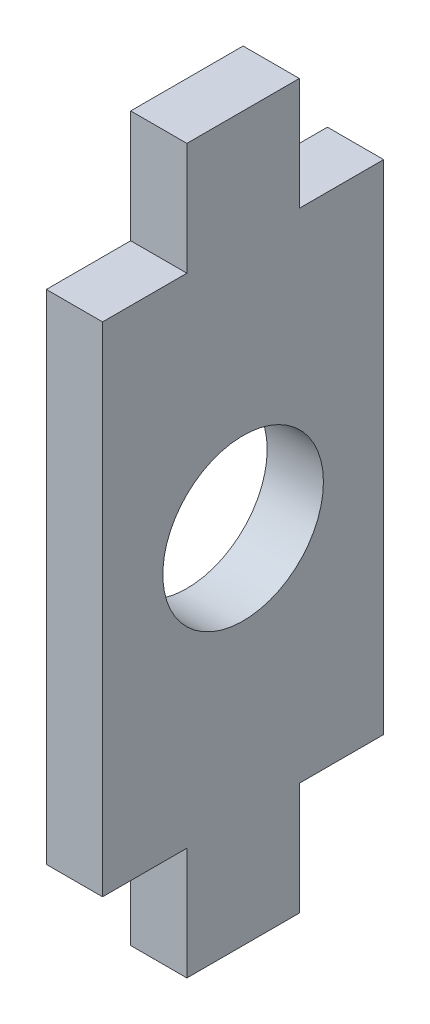
from build123d import *

# Parameters (mm, degrees)
BOSS_EXTRUDE1_DEPTH = 7
SKETCH2_R           = 10
CUT_EXTRUDE1_DEPTH  = 8


with BuildPart() as part:
    # Sketch1 → Boss-Extrude1 (new body)
    with BuildSketch(Plane(origin=(0, 0, 0), x_dir=(0, 0, -1), z_dir=(1, 0, 0))):
        Polygon((-7, -31), (-7, -45), (7, -45), (7, -31), (17.5, -31), (17.5, 31), (7, 31), (7, 45), (-7, 45), (-7, 31), (-17.5, 31), (-17.5, -31), align=None)
    extrude(amount=BOSS_EXTRUDE1_DEPTH)

    # Sketch2 → Cut-Extrude1 (cut, through all)
    with BuildSketch(Plane(origin=(7, 0, 0), x_dir=(0, 0, -1), z_dir=(1, 0, 0))):
        Circle(SKETCH2_R)
    extrude(amount=-CUT_EXTRUDE1_DEPTH, mode=Mode.SUBTRACT)


solid = part.part
